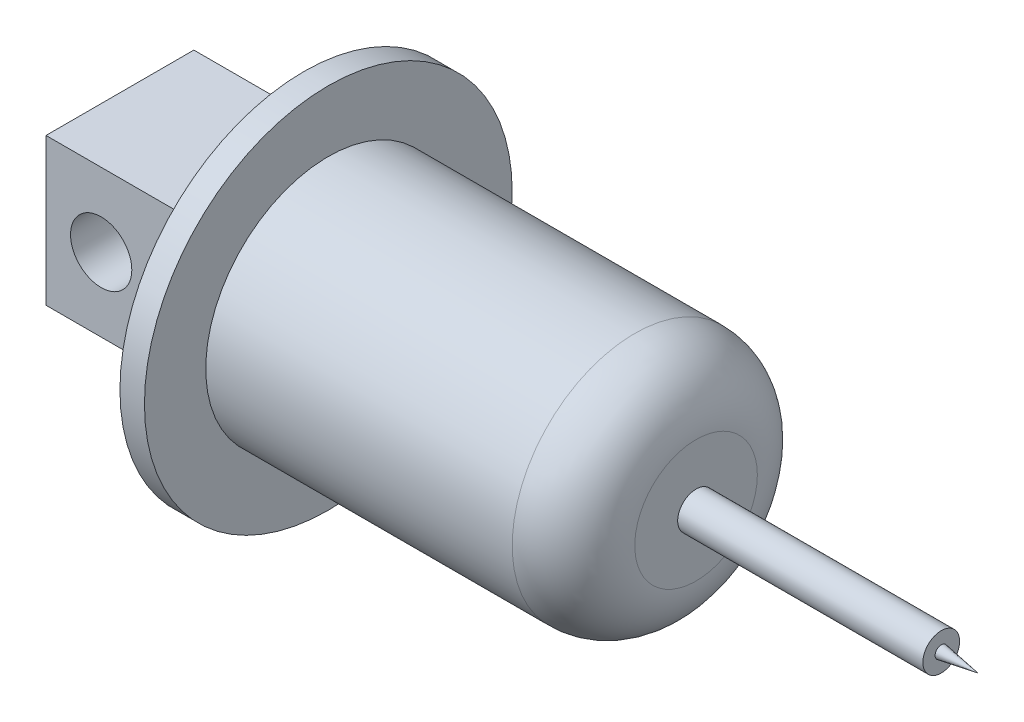
from build123d import *

# Parameters (mm, degrees)
SKETCH1_R             = 10
BOSS_EXTRUDE1_DEPTH   = 30
SKETCH4_R             = 15
BOSS_EXTRUDE2_DEPTH   = 2
FILLET1_R             = 5
SKETCH6_R             = 1.5
BOSS_EXTRUDE3_DEPTH   = 20
SKETCH7_W             = 12.06257879
SKETCH7_H             = 12
BOSS_EXTRUDE4_DEPTH   = 15
SKETCH8_R             = 2.5
CUT_EXTRUDE2_DEPTH    = 22.031289395
BODY_MOVE_COPY5_ANGLE = 90


with BuildPart() as part:
    # Sketch1 → Boss-Extrude1 (new body)
    with BuildSketch(Plane.XY):
        Circle(SKETCH1_R)
    extrude(amount=BOSS_EXTRUDE1_DEPTH)

    # Sketch4 → Boss-Extrude2 (add)
    with BuildSketch(Plane(origin=(0, 0, 0), x_dir=(-1, 0, 0), z_dir=(0, 0, -1))):
        Circle(SKETCH4_R)
    extrude(amount=BOSS_EXTRUDE2_DEPTH)

    # Fillet1
    fillet1_edges = [part.edges().sort_by_distance(p)[0] for p in [
        (-10, 0, 30),
    ]]
    fillet(fillet1_edges, radius=FILLET1_R)

    # Sketch6 → Boss-Extrude3 (add)
    with BuildSketch(Plane.XY.offset(30)):
        Circle(SKETCH6_R)
    extrude(amount=BOSS_EXTRUDE3_DEPTH)

    # Sketch7 → Boss-Extrude4 (add)
    with BuildSketch(Plane(origin=(0, 0, -2), x_dir=(-1, 0, 0), z_dir=(0, 0, -1))):
        Rectangle(SKETCH7_W, SKETCH7_H)
    extrude(amount=BOSS_EXTRUDE4_DEPTH)

    # Sketch8 → Cut-Extrude2 (cut, through all)
    with BuildSketch(Plane.ZY.offset(6.031289395)):
        with Locations((-12.5, 0)):
            Circle(SKETCH8_R)
    extrude(amount=-CUT_EXTRUDE2_DEPTH, mode=Mode.SUBTRACT)

    # Sketch15 → Revolve2 (revolve)
    with BuildSketch(Plane(origin=(0, 0, 0), x_dir=(1, 0, 0), z_dir=(0, 1, 0))):
        Polygon((0.5, -50), (0, -53), (0, -50), align=None)
    revolve(axis=Axis((0, 0, 50), (0, 0, 1)))


with BuildPart() as part_1:
    # Body-Move/Copy3: moved
    add(part.part.moved(Location((0, 0, -50))))


with BuildPart() as part_2:
    # Body-Move/Copy5: moved
    add(part_1.part.rotate(Axis((0, 0, 0), (0, 1, 0)), BODY_MOVE_COPY5_ANGLE))


solid = part_2.part
